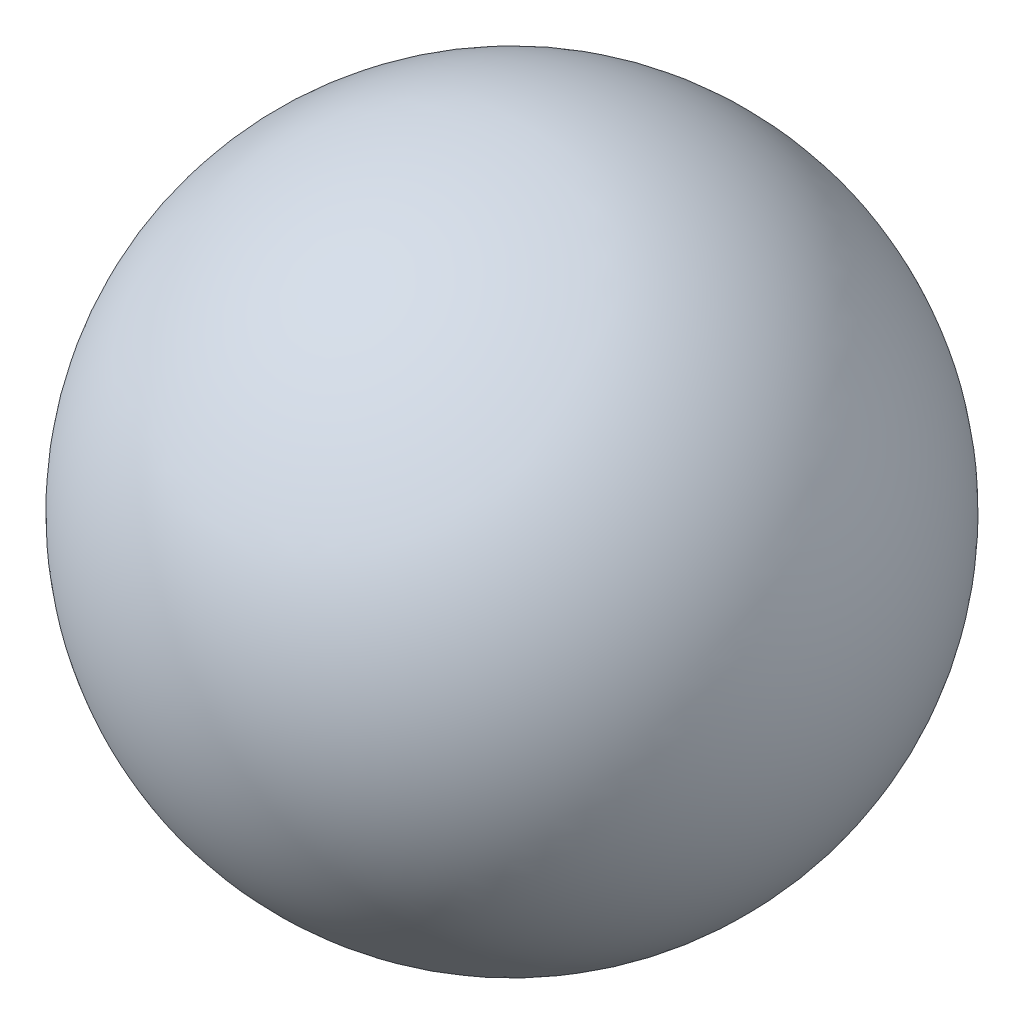
from build123d import *


with BuildPart() as part:
    # Sketch1 → Revolve1 (revolve)
    with BuildSketch(Plane(origin=(0, 0, 0), x_dir=(1, 0, 0), z_dir=(0, 1, 0))):
        with BuildLine():
            Line((0, 20), (0, -20))
            ThreePointArc((0, -20), (-20, 0), (0, 20))
        make_face()
    revolve(axis=Axis((0, 0, -20), (0, 0, 1)))


solid = part.part
